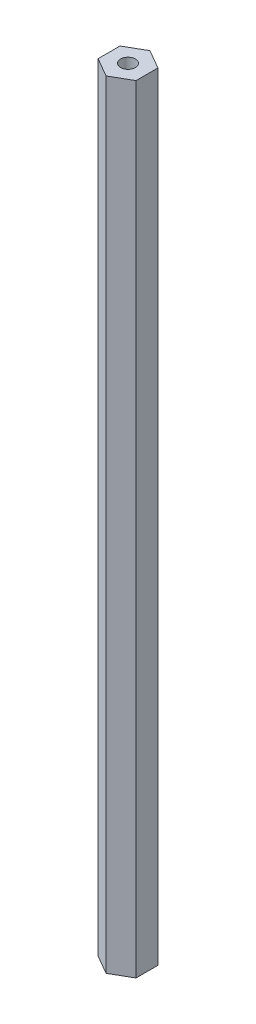
from build123d import *

# Parameters (mm, degrees)
BOSS_EXTRUDE1_DEPTH       = 130
M6X1_0_TAPPED_HOLE1_D     = 5
M6X1_0_TAPPED_HOLE1_DEPTH = 15
M6X1_0_TAPPED_HOLE1_TIP   = 1.502151548
M6X1_0_TAPPED_HOLE2_D     = 5
M6X1_0_TAPPED_HOLE2_DEPTH = 15
M6X1_0_TAPPED_HOLE2_TIP   = 1.502151548


with BuildPart() as part:
    # Sketch1 → Boss-Extrude1 (new, symmetric)
    with BuildSketch(Plane(origin=(0, 0, 0), x_dir=(1, 0, 0), z_dir=(0, 1, 0))):
        Polygon((6.349472256, -3.667088137), (6.350527612, 3.665260206), (0.001055356, 7.332348343), (-6.349472256, 3.667088137), (-6.350527612, -3.665260206), (-0.001055356, -7.332348343), align=None)
    extrude(amount=BOSS_EXTRUDE1_DEPTH, both=True)

    # M6x1.0 Tapped Hole1
    with Locations(Plane(origin=(0, 130, 0), x_dir=(1, 0, 0), z_dir=(0, 1, 0))):
        with Locations((0, 0)):
            Hole(M6X1_0_TAPPED_HOLE1_D / 2, depth=M6X1_0_TAPPED_HOLE1_DEPTH)
            with Locations((0, 0, -(M6X1_0_TAPPED_HOLE1_DEPTH + M6X1_0_TAPPED_HOLE1_TIP / 2))):  # 118° drill point
                Cone(0, M6X1_0_TAPPED_HOLE1_D / 2, M6X1_0_TAPPED_HOLE1_TIP, mode=Mode.SUBTRACT)

    # M6x1.0 Tapped Hole2
    with Locations(Plane(origin=(0, -130, 0), x_dir=(-1, 0, 0), z_dir=(0, -1, 0))):
        with Locations((0, 0)):
            Hole(M6X1_0_TAPPED_HOLE2_D / 2, depth=M6X1_0_TAPPED_HOLE2_DEPTH)
            with Locations((0, 0, -(M6X1_0_TAPPED_HOLE2_DEPTH + M6X1_0_TAPPED_HOLE2_TIP / 2))):  # 118° drill point
                Cone(0, M6X1_0_TAPPED_HOLE2_D / 2, M6X1_0_TAPPED_HOLE2_TIP, mode=Mode.SUBTRACT)


solid = part.part
